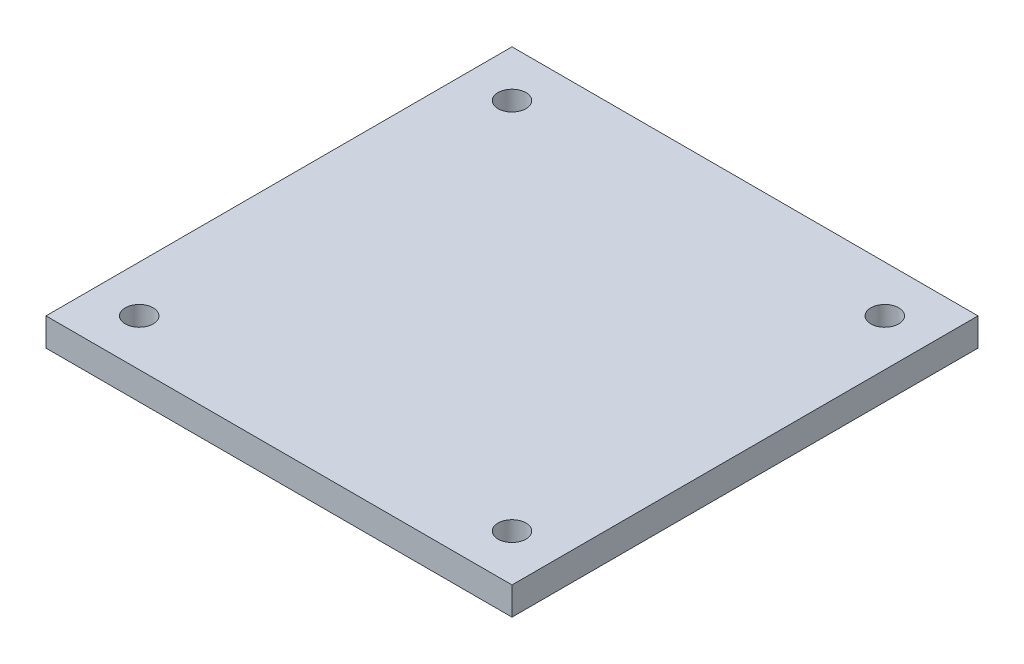
from build123d import *

# Parameters (mm, degrees)
SKETCH1_W           = 50
SKETCH1_H           = 50
SKETCH1_R           = 1.5
BOSS_EXTRUDE1_DEPTH = 3


with BuildPart() as part:
    # Sketch1 → Boss-Extrude1 (new body)
    with BuildSketch(Plane(origin=(0, 0, 0), x_dir=(1, 0, 0), z_dir=(0, 1, 0))):
        Rectangle(SKETCH1_W, SKETCH1_H)
        with Locations((20, 20)):
            Circle(SKETCH1_R, mode=Mode.SUBTRACT)
        with Locations((-20, 20)):
            Circle(SKETCH1_R, mode=Mode.SUBTRACT)
        with Locations((20, -20)):
            Circle(SKETCH1_R, mode=Mode.SUBTRACT)
        with Locations((-20, -20)):
            Circle(SKETCH1_R, mode=Mode.SUBTRACT)
    extrude(amount=BOSS_EXTRUDE1_DEPTH)


solid = part.part
